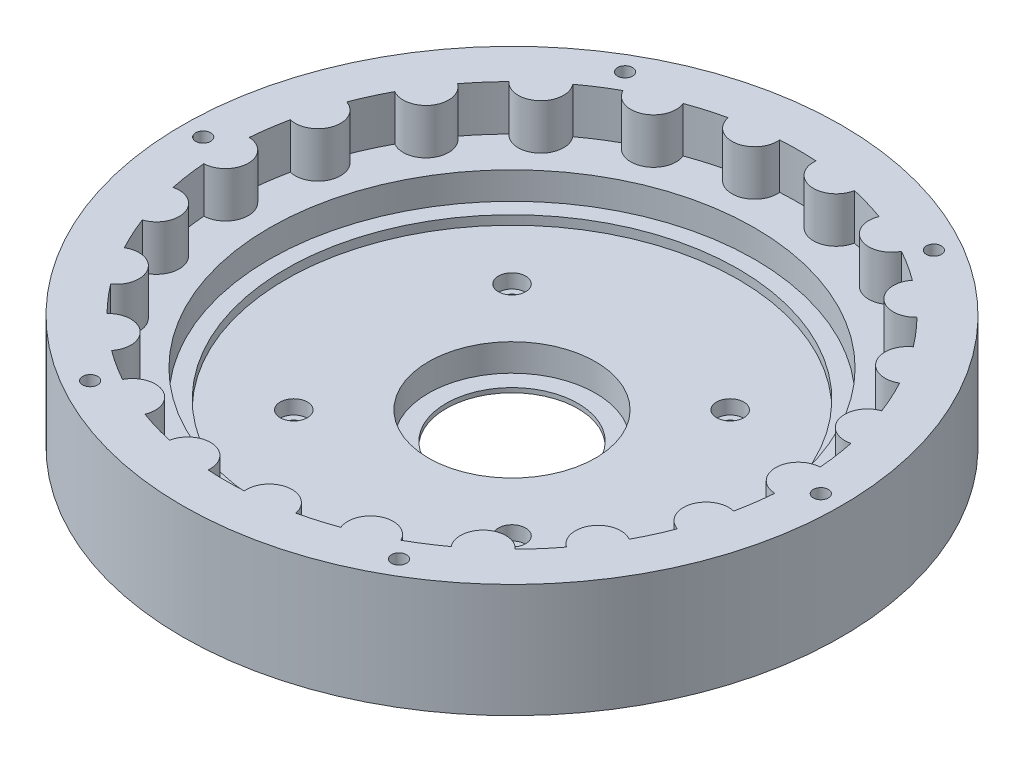
from build123d import *

# Parameters (mm, degrees)
SKETCH1_R           = 72.5
BOSS_EXTRUDE1_DEPTH = 25
SKETCH1_4_R         = 72.5
SKETCH1_4_R_2       = 14.5
BOSS_EXTRUDE2_DEPTH = 1
SKETCH1_5_R         = 72.5
SKETCH1_5_R_2       = 18.375
BOSS_EXTRUDE3_DEPTH = 7
SKETCH1_8_R         = 72.5
SKETCH1_8_R_2       = 49.75
BOSS_EXTRUDE5_DEPTH = 9
SKETCH1_10_R        = 72.5
SKETCH1_10_R_2      = 53.375
BOSS_EXTRUDE6_DEPTH = 15
SKETCH1_11_R        = 1.65
CUT_EXTRUDE1_DEPTH  = 26
SKETCH1_12_R        = 3
CUT_EXTRUDE2_DEPTH  = 8
SKETCH1_15_R        = 1.65
CUT_EXTRUDE3_DEPTH  = 20
CUT_EXTRUDE4_START  = 7
SKETCH1_16_R        = 3
CUT_EXTRUDE4_DEPTH  = 3.1


with BuildPart() as part:
    # Sketch1 → Boss-Extrude1 (new body)
    with BuildSketch(Plane(origin=(0, 0, 0), x_dir=(1, 0, 0), z_dir=(0, 1, 0))):
        with Locations((-0.792166463, -0.608066556)):
            Circle(SKETCH1_R)
        with BuildLine():
            ThreePointArc((-63.593753764, -5.604128245), (-58.792166463, -0.608066556), (-63.593753764, 4.387995133))
            ThreePointArc((-63.593753764, 4.387995133), (-63.150917301, 8.357768256), (-62.457401444, 12.291499122))
            ThreePointArc((-62.457401444, 12.291499122), (-56.442758932, 15.732421741), (-59.642294977, 21.878871295))
            ThreePointArc((-59.642294977, 21.878871295), (-58.09898217, 25.563079263), (-56.325298523, 29.142080394))
            ThreePointArc((-56.325298523, 29.142080394), (-49.584871367, 30.749100857), (-50.923148772, 37.547989487))
            ThreePointArc((-50.923148772, 37.547989487), (-48.404389647, 40.648159683), (-45.694231511, 43.582481692))
            ThreePointArc((-45.694231511, 43.582481692), (-38.774089031, 43.225408757), (-38.142688521, 50.125930941))
            ThreePointArc((-38.142688521, 50.125930941), (-34.852537962, 52.390906013), (-31.425466231, 54.442827581))
            ThreePointArc((-31.425466231, 54.442827581), (-24.886237217, 52.150589175), (-22.336311105, 58.593705644))
            ThreePointArc((-22.336311105, 58.593705644), (-18.541317544, 59.839990782), (-14.674973188, 60.843277428))
            ThreePointArc((-14.674973188, 60.843277428), (-9.046427083, 56.801577073), (-4.784555218, 62.265304851))
            ThreePointArc((-4.784555218, 62.265304851), (-0.792166463, 62.391933444), (3.200222293, 62.265304851))
            ThreePointArc((3.200222293, 62.265304851), (7.462094157, 56.801577073), (13.090640262, 60.843277428))
            ThreePointArc((13.090640262, 60.843277428), (16.956984618, 59.839990782), (20.75197818, 58.593705644))
            ThreePointArc((20.75197818, 58.593705644), (23.301904291, 52.150589175), (29.841133306, 54.442827581))
            ThreePointArc((29.841133306, 54.442827581), (33.268205037, 52.390906013), (36.558355596, 50.125930941))
            ThreePointArc((36.558355596, 50.125930941), (37.189756106, 43.225408757), (44.109898586, 43.582481692))
            ThreePointArc((44.109898586, 43.582481692), (46.820056722, 40.648159683), (49.338815847, 37.547989487))
            ThreePointArc((49.338815847, 37.547989487), (48.000538442, 30.749100857), (54.740965598, 29.142080394))
            ThreePointArc((54.740965598, 29.142080394), (56.514649245, 25.563079263), (58.057962051, 21.878871295))
            ThreePointArc((58.057962051, 21.878871295), (54.858426007, 15.732421741), (60.873068519, 12.291499122))
            ThreePointArc((60.873068519, 12.291499122), (61.566584376, 8.357768256), (62.009420839, 4.387995133))
            ThreePointArc((62.009420839, 4.387995133), (57.207833537, -0.608066556), (62.009420839, -5.604128245))
            ThreePointArc((62.009420839, -5.604128245), (61.566584376, -9.573901367), (60.873068519, -13.507632233))
            ThreePointArc((60.873068519, -13.507632233), (54.858426007, -16.948554852), (58.057962051, -23.095004406))
            ThreePointArc((58.057962051, -23.095004406), (56.514649245, -26.779212375), (54.740965598, -30.358213506))
            ThreePointArc((54.740965598, -30.358213506), (48.000538442, -31.965233968), (49.338815847, -38.764122598))
            ThreePointArc((49.338815847, -38.764122598), (46.820056722, -41.864292794), (44.109898586, -44.798614803))
            ThreePointArc((44.109898586, -44.798614803), (37.189756106, -44.441541868), (36.558355596, -51.342064052))
            ThreePointArc((36.558355596, -51.342064052), (33.268205037, -53.607039124), (29.841133306, -55.658960693))
            ThreePointArc((29.841133306, -55.658960693), (23.301904291, -53.366722286), (20.75197818, -59.809838756))
            ThreePointArc((20.75197818, -59.809838756), (16.956984618, -61.056123893), (13.090640262, -62.05941054))
            ThreePointArc((13.090640262, -62.05941054), (7.462094157, -58.017710185), (3.200222293, -63.481437962))
            ThreePointArc((3.200222293, -63.481437962), (-0.792166463, -63.608066556), (-4.784555218, -63.481437962))
            ThreePointArc((-4.784555218, -63.481437962), (-9.046427083, -58.017710185), (-14.674973188, -62.05941054))
            ThreePointArc((-14.674973188, -62.05941054), (-18.541317544, -61.056123893), (-22.336311105, -59.809838756))
            ThreePointArc((-22.336311105, -59.809838756), (-24.886237217, -53.366722286), (-31.425466231, -55.658960693))
            ThreePointArc((-31.425466231, -55.658960693), (-34.852537962, -53.607039124), (-38.142688521, -51.342064052))
            ThreePointArc((-38.142688521, -51.342064052), (-38.774089031, -44.441541868), (-45.694231511, -44.798614803))
            ThreePointArc((-45.694231511, -44.798614803), (-48.404389647, -41.864292794), (-50.923148772, -38.764122598))
            ThreePointArc((-50.923148772, -38.764122598), (-49.584871367, -31.965233968), (-56.325298523, -30.358213506))
            ThreePointArc((-56.325298523, -30.358213506), (-58.09898217, -26.779212375), (-59.642294977, -23.095004406))
            ThreePointArc((-59.642294977, -23.095004406), (-56.442758932, -16.948554852), (-62.457401444, -13.507632233))
            ThreePointArc((-62.457401444, -13.507632233), (-63.150917301, -9.573901367), (-63.593753764, -5.604128245))
        make_face(mode=Mode.SUBTRACT)
    extrude(amount=BOSS_EXTRUDE1_DEPTH)

    # Sketch1_4 → Boss-Extrude2 (add)
    with BuildSketch(Plane(origin=(0, 0, 0), x_dir=(1, 0, 0), z_dir=(0, 1, 0))):
        with Locations((-0.792166463, -0.608066556)):
            Circle(SKETCH1_4_R)
        with Locations((-0.792166463, -0.608066556)):
            Circle(SKETCH1_4_R_2, mode=Mode.SUBTRACT)
    extrude(amount=BOSS_EXTRUDE2_DEPTH)

    # Sketch1_5 → Boss-Extrude3 (add)
    with BuildSketch(Plane(origin=(0, 0, 0), x_dir=(1, 0, 0), z_dir=(0, 1, 0))):
        with Locations((-0.792166463, -0.608066556)):
            Circle(SKETCH1_5_R)
        with Locations((-0.792166463, -0.608066556)):
            Circle(SKETCH1_5_R_2, mode=Mode.SUBTRACT)
    extrude(amount=BOSS_EXTRUDE3_DEPTH)

    # Sketch1_8 → Boss-Extrude5 (add)
    with BuildSketch(Plane(origin=(0, 0, 0), x_dir=(1, 0, 0), z_dir=(0, 1, 0))):
        with Locations((-0.792166463, -0.608066556)):
            Circle(SKETCH1_8_R)
        with Locations((-0.792166463, -0.608066556)):
            Circle(SKETCH1_8_R_2, mode=Mode.SUBTRACT)
    extrude(amount=BOSS_EXTRUDE5_DEPTH)

    # Sketch1_10 → Boss-Extrude6 (add)
    with BuildSketch(Plane(origin=(0, 0, 0), x_dir=(1, 0, 0), z_dir=(0, 1, 0))):
        with Locations((-0.792166463, -0.608066556)):
            Circle(SKETCH1_10_R)
        with Locations((-0.792166463, -0.608066556)):
            Circle(SKETCH1_10_R_2, mode=Mode.SUBTRACT)
    extrude(amount=BOSS_EXTRUDE6_DEPTH)

    # Sketch1_11 → Cut-Extrude1 (cut, through all)
    with BuildSketch(Plane(origin=(0, 0, 0), x_dir=(1, 0, 0), z_dir=(0, 1, 0))):
        with Locations((-68.730033322, -0.608066556)):
            Circle(SKETCH1_11_R)
        with Locations((-34.761099892, 58.227852024)):
            Circle(SKETCH1_11_R)
        with Locations((33.176766967, 58.227852024)):
            Circle(SKETCH1_11_R)
        with Locations((67.145700397, -0.608066556)):
            Circle(SKETCH1_11_R)
        with Locations((33.176766967, -59.443985135)):
            Circle(SKETCH1_11_R)
        with Locations((-34.761099892, -59.443985135)):
            Circle(SKETCH1_11_R)
    extrude(amount=CUT_EXTRUDE1_DEPTH, mode=Mode.SUBTRACT)

    # Sketch1_12 → Cut-Extrude2 (cut)
    with BuildSketch(Plane(origin=(0, 0, 0), x_dir=(1, 0, 0), z_dir=(0, 1, 0))):
        with Locations((-68.730033322, -0.608066556)):
            Circle(SKETCH1_12_R)
        with Locations((-34.761099892, 58.227852024)):
            Circle(SKETCH1_12_R)
        with Locations((33.176766967, 58.227852024)):
            Circle(SKETCH1_12_R)
        with Locations((67.145700397, -0.608066556)):
            Circle(SKETCH1_12_R)
        with Locations((33.176766967, -59.443985135)):
            Circle(SKETCH1_12_R)
        with Locations((-34.761099892, -59.443985135)):
            Circle(SKETCH1_12_R)
    extrude(amount=CUT_EXTRUDE2_DEPTH, mode=Mode.SUBTRACT)

    # Sketch1_15 → Cut-Extrude3 (cut)
    with BuildSketch(Plane(origin=(0, 0, 0), x_dir=(1, 0, 0), z_dir=(0, 1, 0))):
        with Locations((-24.792166462, 23.391933444)):
            Circle(SKETCH1_15_R)
        with Locations((23.207833537, 23.391933444)):
            Circle(SKETCH1_15_R)
        with Locations((23.207833537, -24.608066556)):
            Circle(SKETCH1_15_R)
        with Locations((-24.792166463, -24.608066555)):
            Circle(SKETCH1_15_R)
    extrude(amount=CUT_EXTRUDE3_DEPTH, mode=Mode.SUBTRACT)

    # Sketch1_16 → Cut-Extrude4 (cut)
    with BuildSketch(Plane(origin=(0, 0, 0), x_dir=(1, 0, 0), z_dir=(0, 1, 0)).offset(CUT_EXTRUDE4_START)):
        with Locations((-24.792166462, 23.391933444)):
            Circle(SKETCH1_16_R)
        with Locations((23.207833537, 23.391933444)):
            Circle(SKETCH1_16_R)
        with Locations((23.207833537, -24.608066556)):
            Circle(SKETCH1_16_R)
        with Locations((-24.792166463, -24.608066555)):
            Circle(SKETCH1_16_R)
    extrude(amount=-CUT_EXTRUDE4_DEPTH, mode=Mode.SUBTRACT)


solid = part.part
